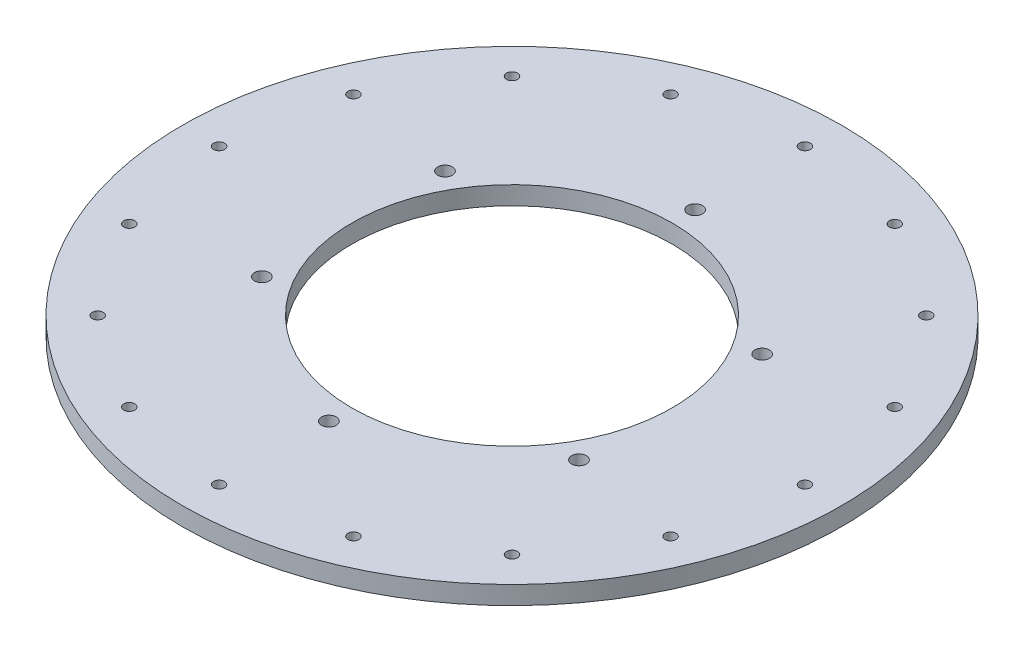
from build123d import *

# Parameters (mm, degrees)
SKETCH1_R           = 180
SKETCH1_R_2         = 87.5
SKETCH1_R_3         = 3
SKETCH1_R_4         = 4
BOSS_EXTRUDE1_DEPTH = 10


with BuildPart() as part:
    # Sketch1 → Boss-Extrude1 (new body)
    with BuildSketch(Plane(origin=(0, 0, 0), x_dir=(1, 0, 0), z_dir=(0, 1, 0))):
        Circle(SKETCH1_R)
        Circle(SKETCH1_R_2, mode=Mode.SUBTRACT)
        with Locations((0, 160)):
            Circle(SKETCH1_R_3, mode=Mode.SUBTRACT)
        with Locations((61.229349178, 147.820725202)):
            Circle(SKETCH1_R_3, mode=Mode.SUBTRACT)
        with Locations((113.13708499, 113.13708499)):
            Circle(SKETCH1_R_3, mode=Mode.SUBTRACT)
        with Locations((147.820725202, 61.229349178)):
            Circle(SKETCH1_R_3, mode=Mode.SUBTRACT)
        with Locations((160, 0)):
            Circle(SKETCH1_R_3, mode=Mode.SUBTRACT)
        with Locations((147.820725202, -61.229349178)):
            Circle(SKETCH1_R_3, mode=Mode.SUBTRACT)
        with Locations((113.13708499, -113.13708499)):
            Circle(SKETCH1_R_3, mode=Mode.SUBTRACT)
        with Locations((61.229349178, -147.820725202)):
            Circle(SKETCH1_R_3, mode=Mode.SUBTRACT)
        with Locations((0, -160)):
            Circle(SKETCH1_R_3, mode=Mode.SUBTRACT)
        with Locations((-61.229349178, -147.820725202)):
            Circle(SKETCH1_R_3, mode=Mode.SUBTRACT)
        with Locations((-113.13708499, -113.13708499)):
            Circle(SKETCH1_R_3, mode=Mode.SUBTRACT)
        with Locations((-147.820725202, -61.229349178)):
            Circle(SKETCH1_R_3, mode=Mode.SUBTRACT)
        with Locations((-160, 0)):
            Circle(SKETCH1_R_3, mode=Mode.SUBTRACT)
        with Locations((-147.820725202, 61.229349178)):
            Circle(SKETCH1_R_3, mode=Mode.SUBTRACT)
        with Locations((-113.13708499, 113.13708499)):
            Circle(SKETCH1_R_3, mode=Mode.SUBTRACT)
        with Locations((-61.229349178, 147.820725202)):
            Circle(SKETCH1_R_3, mode=Mode.SUBTRACT)
        with Locations((0, 100)):
            Circle(SKETCH1_R_4, mode=Mode.SUBTRACT)
        with Locations((86.602540378, 50)):
            Circle(SKETCH1_R_4, mode=Mode.SUBTRACT)
        with Locations((86.602540378, -50)):
            Circle(SKETCH1_R_4, mode=Mode.SUBTRACT)
        with Locations((0, -100)):
            Circle(SKETCH1_R_4, mode=Mode.SUBTRACT)
        with Locations((-86.602540378, -50)):
            Circle(SKETCH1_R_4, mode=Mode.SUBTRACT)
        with Locations((-86.602540378, 50)):
            Circle(SKETCH1_R_4, mode=Mode.SUBTRACT)
    extrude(amount=BOSS_EXTRUDE1_DEPTH)


solid = part.part
